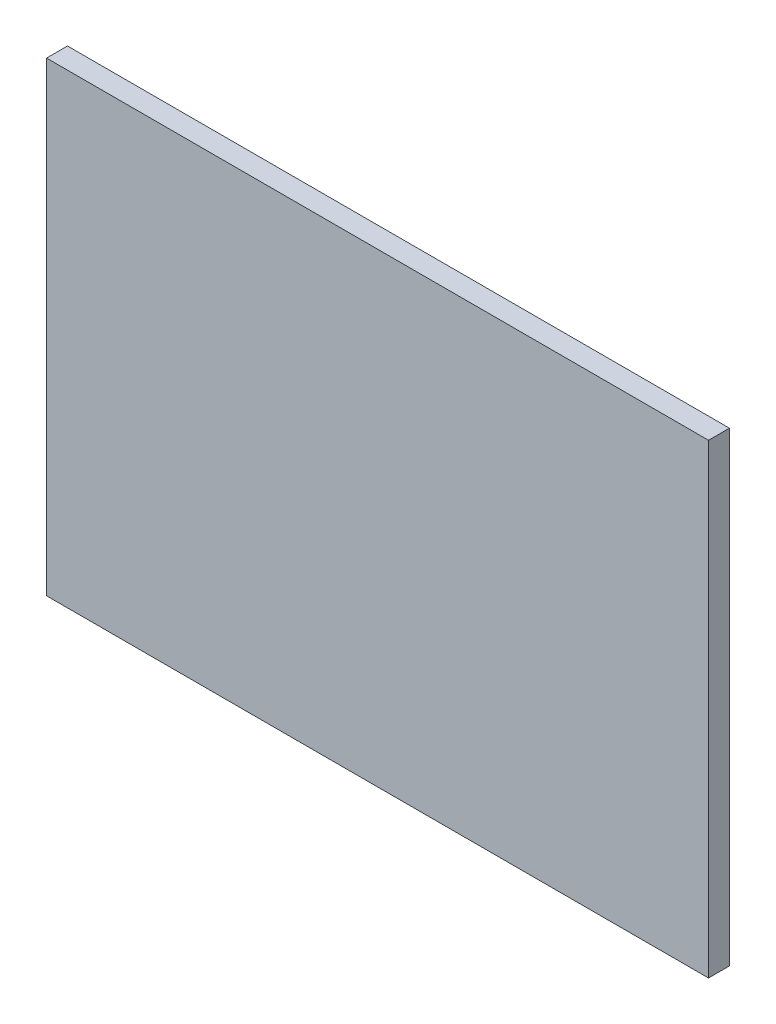
from build123d import *

# Parameters (mm, degrees)
SKETCH_1_W      = 25.3
SKETCH_1_H      = 17.8
EXTRUDE_1_DEPTH = 0.8


with BuildPart() as part:
    # Эскиз1 → Бобышка-Вытянуть1 (new body)
    with BuildSketch(Plane.XY):
        Rectangle(SKETCH_1_W, SKETCH_1_H)
    extrude(amount=EXTRUDE_1_DEPTH)


solid = part.part
